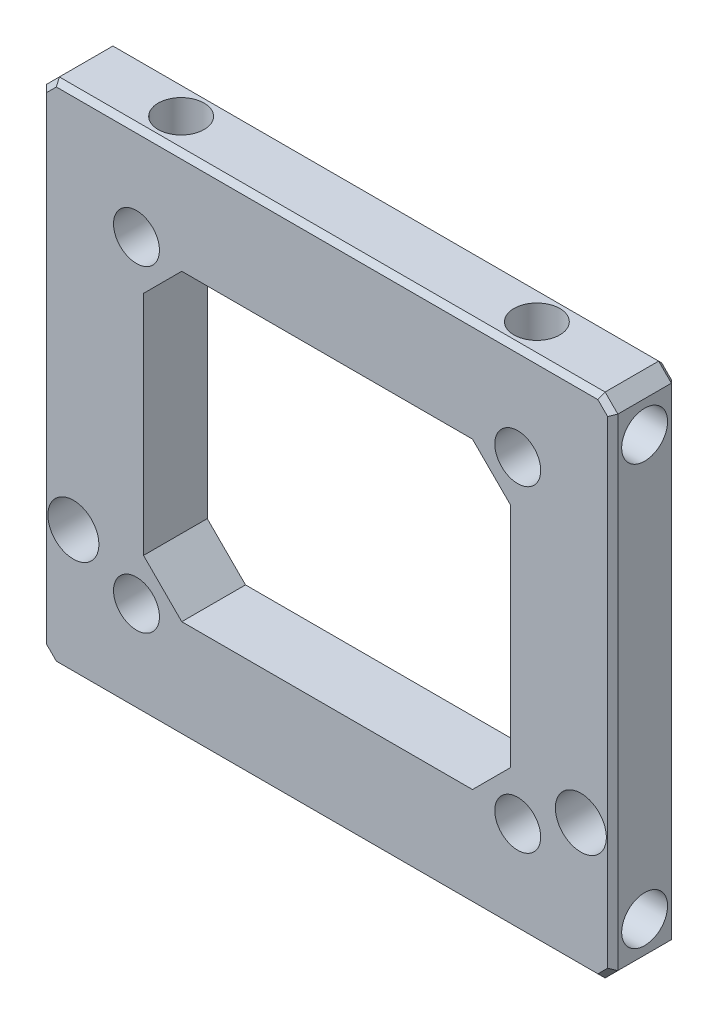
from build123d import *

# Parameters (mm, degrees)
SKETCH2_W               = 44.8
SKETCH2_H               = 39.8
SKETCH2_W_2             = 28.8
SKETCH2_H_2             = 23.8
BOSS_EXTRUDE1_DEPTH     = 5
CHAMFER1_SIZE           = 1
CHAMFER2_SIZE           = 3
SKETCH3_R               = 1.8
CUT_EXTRUDE1_DEPTH      = 6
SKETCH4_R               = 1.8
CUT_EXTRUDE2_DEPTH      = 5
SKETCH5_R               = 1.8
CUT_EXTRUDE3_DEPTH      = 5
MIRROR2_COPY_1_SKETCH_R = 1.8
MIRROR2_COPY_1_DEPTH    = 6
MIRROR2_COPY_2_SKETCH_R = 1.8
MIRROR2_COPY_2_DEPTH    = 5
MIRROR2_COPY_3_SKETCH_R = 1.8
MIRROR2_COPY_3_DEPTH    = 5
SKETCH6_R               = 2
CUT_EXTRUDE4_DEPTH      = 6
CHAMFER3_SIZE           = 0.4


with BuildPart() as part:
    # Sketch2 → Boss-Extrude1 (new body)
    with BuildSketch(Plane.XY):
        Rectangle(SKETCH2_W, SKETCH2_H)
        Rectangle(SKETCH2_W_2, SKETCH2_H_2, mode=Mode.SUBTRACT)
    extrude(amount=BOSS_EXTRUDE1_DEPTH)

    # Chamfer1
    chamfer1_edges = [part.edges().sort_by_distance(p)[0] for p in [
        (-22.4, 19.9, 2.5),
        (22.4, 19.9, 2.5),
        (22.4, -19.9, 2.5),
        (-22.4, -19.9, 2.5),
    ]]
    chamfer(chamfer1_edges, length=CHAMFER1_SIZE)

    # Chamfer2
    chamfer2_edges = [part.edges().sort_by_distance(p)[0] for p in [
        (-14.4, 11.9, 2.5),
        (-14.4, -11.9, 2.5),
        (14.4, -11.9, 2.5),
        (14.4, 11.9, 2.5),
    ]]
    chamfer(chamfer2_edges, length=CHAMFER2_SIZE)

    # Sketch3 → Cut-Extrude1 (cut, through all)
    with BuildSketch(Plane.XY.offset(5)):
        with Locations((14.95, 12.45)):
            Circle(SKETCH3_R)
    cut_extrude1 = extrude(amount=-CUT_EXTRUDE1_DEPTH, mode=Mode.SUBTRACT)

    # Sketch4 → Cut-Extrude2 (cut)
    with BuildSketch(Plane(origin=(0, 19.9, 0), x_dir=(1, 0, 0), z_dir=(0, 1, 0))):
        with Locations((13.95, -2.5)):
            Circle(SKETCH4_R)
    cut_extrude2 = extrude(amount=-CUT_EXTRUDE2_DEPTH, mode=Mode.SUBTRACT)

    # Sketch5 → Cut-Extrude3 (cut)
    with BuildSketch(Plane(origin=(22.4, 0, 0), x_dir=(0, 0, -1), z_dir=(1, 0, 0))):
        with Locations((-2.5, 16.45)):
            Circle(SKETCH5_R)
    cut_extrude3 = extrude(amount=-CUT_EXTRUDE3_DEPTH, mode=Mode.SUBTRACT)

    # Mirror1: Cut-Extrude1, Cut-Extrude2, Cut-Extrude3 across plane
    add(cut_extrude1.mirror(Plane.ZX), mode=Mode.SUBTRACT)
    add(cut_extrude2.mirror(Plane.ZX), mode=Mode.SUBTRACT)
    add(cut_extrude3.mirror(Plane.ZX), mode=Mode.SUBTRACT)

    # Mirror2: Cut-Extrude1, Cut-Extrude2, Cut-Extrude3 across plane
    add(cut_extrude1.mirror(Plane(origin=(0, 0, 0), x_dir=(0, 0, 1), z_dir=(1, 0, 0))), mode=Mode.SUBTRACT)
    add(cut_extrude2.mirror(Plane(origin=(0, 0, 0), x_dir=(0, 0, 1), z_dir=(1, 0, 0))), mode=Mode.SUBTRACT)
    add(cut_extrude3.mirror(Plane(origin=(0, 0, 0), x_dir=(0, 0, 1), z_dir=(1, 0, 0))), mode=Mode.SUBTRACT)

    # Mirror2 copy 1 sketch → Mirror2 copy 1 (cut, through all)
    with BuildSketch(Plane(origin=(0, 0, 5), x_dir=(-1, 0, 0), z_dir=(0, 0, 1))):
        with Locations((14.95, 12.45)):
            Circle(MIRROR2_COPY_1_SKETCH_R)
    extrude(amount=-MIRROR2_COPY_1_DEPTH, mode=Mode.SUBTRACT)

    # Mirror2 copy 2 sketch → Mirror2 copy 2 (cut)
    with BuildSketch(Plane(origin=(0, -19.9, 0), x_dir=(-1, 0, 0), z_dir=(0, -1, 0))):
        with Locations((13.95, -2.5)):
            Circle(MIRROR2_COPY_2_SKETCH_R)
    extrude(amount=-MIRROR2_COPY_2_DEPTH, mode=Mode.SUBTRACT)

    # Mirror2 copy 3 sketch → Mirror2 copy 3 (cut)
    with BuildSketch(Plane(origin=(-22.4, 0, 0), x_dir=(0, 0, -1), z_dir=(-1, 0, 0))):
        with Locations((-2.5, 16.45)):
            Circle(MIRROR2_COPY_3_SKETCH_R)
    extrude(amount=-MIRROR2_COPY_3_DEPTH, mode=Mode.SUBTRACT)

    # Sketch6 → Cut-Extrude4 (cut, through all)
    with BuildSketch(Plane.XY.offset(5)):
        with Locations((19.9, -9.9)):
            Circle(SKETCH6_R)
        with Locations((-19.9, -9.9)):
            Circle(SKETCH6_R)
    extrude(amount=-CUT_EXTRUDE4_DEPTH, mode=Mode.SUBTRACT)

    # Chamfer3
    chamfer3_edges = [part.edges().sort_by_distance(p)[0] for p in [
        (0, -19.9, 0),
        (0, -19.9, 5),
        (-22.4, 0, 0),
        (0, 19.9, 0),
        (22.4, 0, 0),
        (-21.9, 19.4, 0),
        (21.9, 19.4, 0),
        (21.9, -19.4, 0),
        (-21.9, -19.4, 0),
        (-22.4, 0, 5),
        (22.4, 0, 5),
        (0, 19.9, 5),
        (-21.9, 19.4, 5),
        (21.9, 19.4, 5),
        (21.9, -19.4, 5),
        (-21.9, -19.4, 5),
    ]]
    chamfer(chamfer3_edges, length=CHAMFER3_SIZE)


solid = part.part
